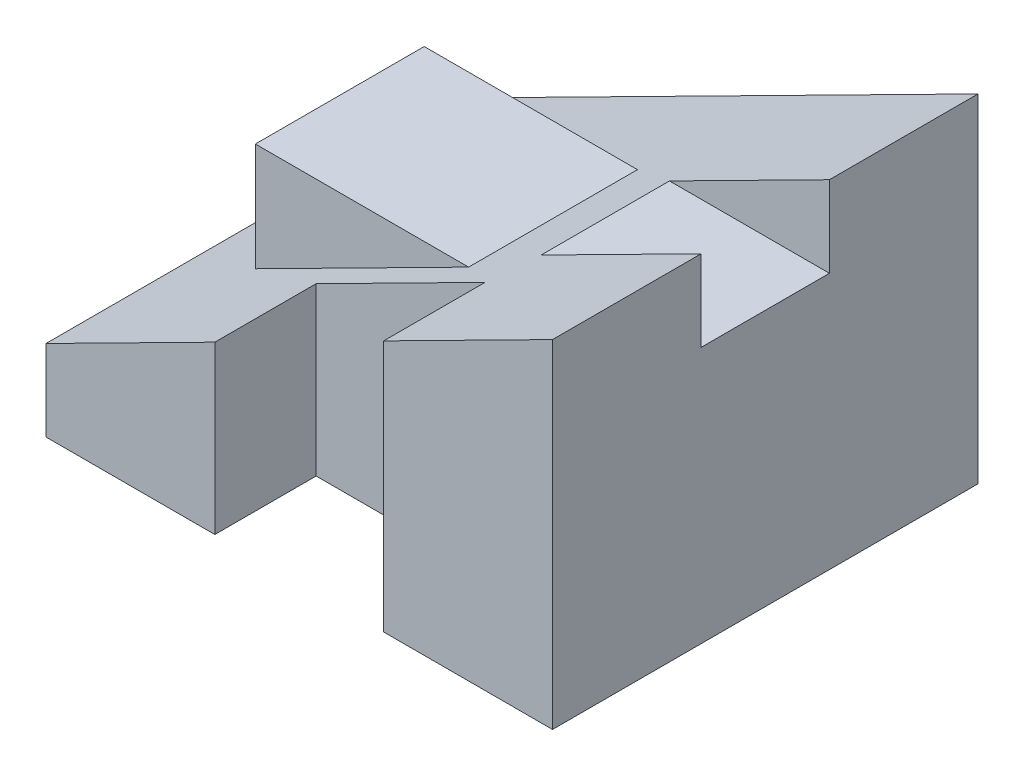
from build123d import *

# Parameters (mm, degrees)
BOSS_EXTRUDE1_DEPTH            = 63
CUT_EXTRUDE1_DEPTH             = 19
CUT_EXTRUDE2_DEPTH             = 19
CUT_EXTRUDE3_REACH             = 36.08
CUT_EXTRUDE3_DIRECTION_2_DEPTH = 16.92
CUT_EXTRUDE4_REACH             = 77
SKETCH6_W                      = 19
SKETCH6_H                      = 12


with BuildPart() as part:
    # Sketch1 → Boss-Extrude1 (new body)
    with BuildSketch(Plane.XY):
        Polygon((38.418907052, 31.947162427), (-36.581092948, -6.052837573), (-36.581092948, -18.052837573), (38.418907052, -18.052837573), align=None)
        Polygon((-24.581092948, 16.027162427), (-24.581092948, 0.027162427), (6.99785442, 16.027162427), align=None)
    extrude(amount=-BOSS_EXTRUDE1_DEPTH)

    # Sketch2 → Cut-Extrude1 (cut)
    with BuildSketch(Plane.XY):
        Polygon((-24.581092948, 16.027162427), (6.99785442, 16.027162427), (-24.581092948, 0.027162427), align=None)
    extrude(amount=-CUT_EXTRUDE1_DEPTH, mode=Mode.SUBTRACT)

    # Sketch3 → Cut-Extrude2 (cut)
    with BuildSketch(Plane(origin=(0, 0, -63), x_dir=(-1, 0, 0), z_dir=(0, 0, -1))):
        Polygon((-6.99785442, 16.027162427), (24.581092948, 16.027162427), (24.581092948, 0.027162427), align=None)
    extrude(amount=-CUT_EXTRUDE2_DEPTH, mode=Mode.SUBTRACT)

    # Sketch4 → Cut-Extrude3 (cut, up to next)
    with BuildSketch(Plane(origin=(0, 16.027162427, 0), x_dir=(1, 0, 0), z_dir=(0, 1, 0)), mode=Mode.PRIVATE) as cut_extrude3_sk1:
        Polygon((-11.581092948, 15), (7.086929483, 15), (13.418907052, 15), (13.418907052, 0), (-11.581092948, 0), align=None)
    cut_extrude3_tool1 = extrude(cut_extrude3_sk1.sketch, amount=-CUT_EXTRUDE3_REACH, mode=Mode.PRIVATE) & part.part
    add(cut_extrude3_tool1.solids().sort_by_distance((0.918907, 16.027162, -7.5))[0], mode=Mode.SUBTRACT)

    # Sketch4 → Cut-Extrude3 direction 2 (cut)
    with BuildSketch(Plane(origin=(0, 16.027162427, 0), x_dir=(1, 0, 0), z_dir=(0, 1, 0))):
        Polygon((-11.581092948, 15), (7.086929483, 15), (13.418907052, 15), (13.418907052, 0), (-11.581092948, 0), align=None)
    extrude(amount=CUT_EXTRUDE3_DIRECTION_2_DEPTH, mode=Mode.SUBTRACT)

    # Sketch6 → Cut-Extrude4 (cut, up to next)
    with BuildSketch(Plane(origin=(38.418907052, 0, 0), x_dir=(0, 0, -1), z_dir=(1, 0, 0)), mode=Mode.PRIVATE) as cut_extrude4_sk1:
        with Locations((31.5, 25.947162427)):
            Rectangle(SKETCH6_W, SKETCH6_H)
    cut_extrude4_tool1 = extrude(cut_extrude4_sk1.sketch, amount=-CUT_EXTRUDE4_REACH, mode=Mode.PRIVATE) & part.part
    add(cut_extrude4_tool1.solids().sort_by_distance((38.418907, 25.947162, -31.5))[0], mode=Mode.SUBTRACT)


solid = part.part
